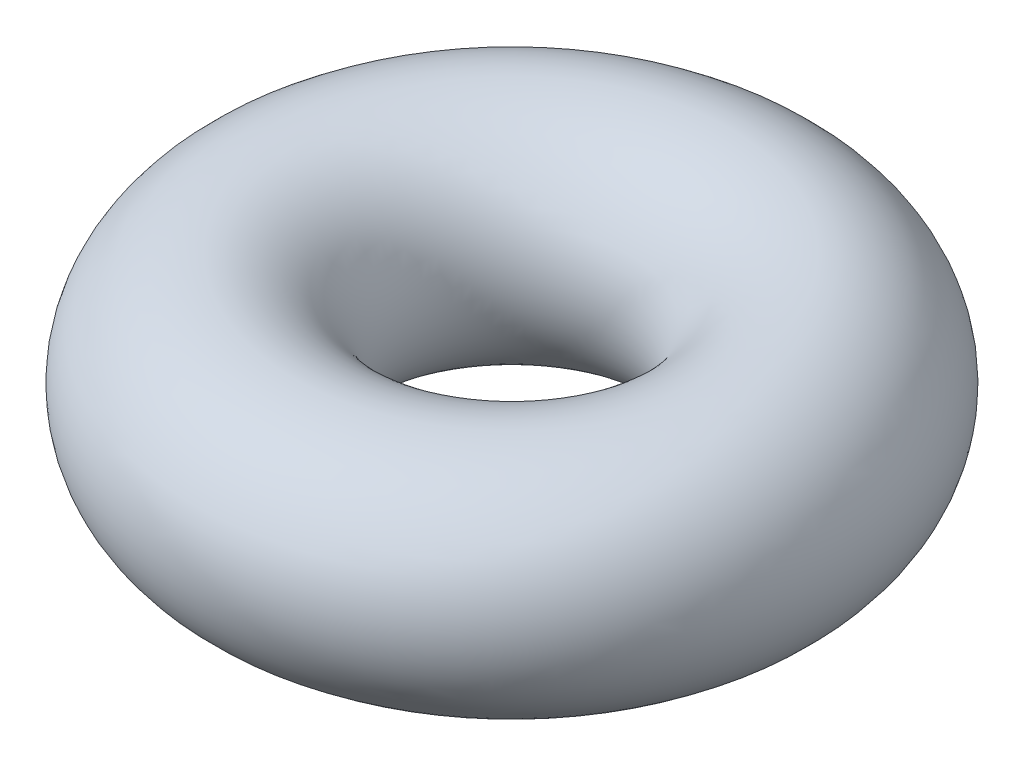
from build123d import *

# Parameters (mm, degrees)
SKETCH2_R = 0.762


with BuildPart() as part:
    # Sketch2 → Revolve1 (revolve)
    with BuildSketch(Plane.XY):
        with Locations((-1.4732, 0)):
            Circle(SKETCH2_R)
    revolve(axis=Axis((0, 0, 0), (0, 1, 0)))


solid = part.part
